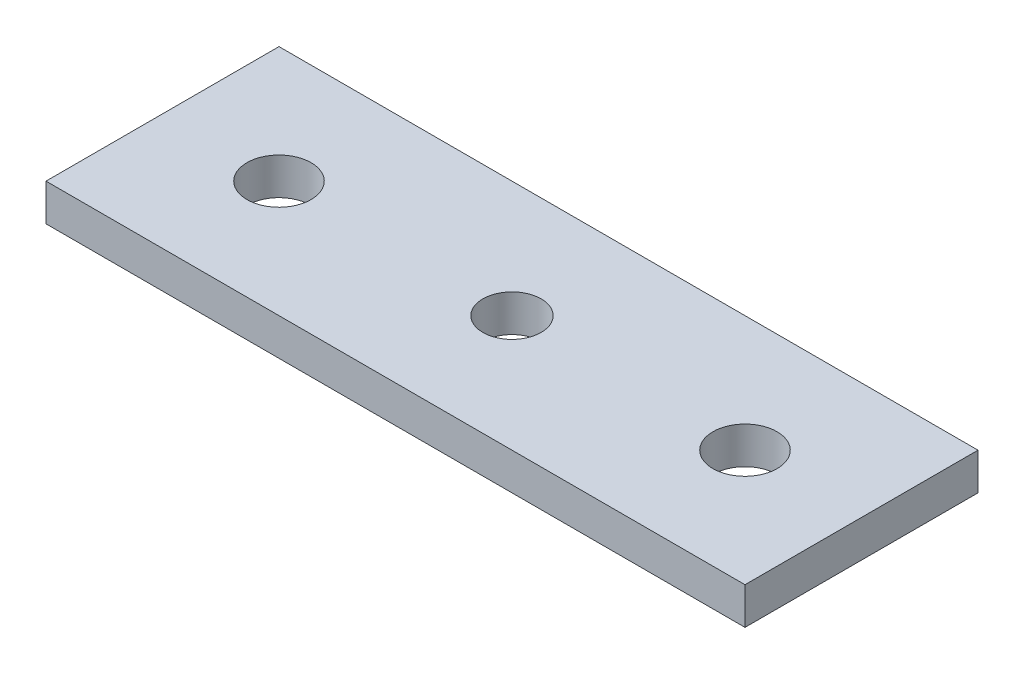
from build123d import *

# Parameters (mm, degrees)
SKETCH1_W             = 60
SKETCH1_H             = 20
BOSS_EXTRUDE1_DEPTH   = 3.175
SKETCH4_R             = 2.75
CUT_EXTRUDE1_DEPTH    = 3.175
M6X1_0_TAPPED_HOLE1_D = 5


with BuildPart() as part:
    # Sketch1 → Boss-Extrude1 (new body)
    with BuildSketch(Plane(origin=(0, 0, 0), x_dir=(1, 0, 0), z_dir=(0, 1, 0))):
        with Locations((30, 10)):
            Rectangle(SKETCH1_W, SKETCH1_H)
    extrude(amount=BOSS_EXTRUDE1_DEPTH)

    # Sketch4 → Cut-Extrude1 (cut)
    with BuildSketch(Plane.XZ):
        with Locations((50, -10)):
            Circle(SKETCH4_R)
        with Locations((10, -10)):
            Circle(SKETCH4_R)
    extrude(amount=-CUT_EXTRUDE1_DEPTH, mode=Mode.SUBTRACT)

    # M6x1.0 Tapped Hole1 (through all)
    with Locations(Plane(origin=(30, 0, -10), x_dir=(0, 0, -1), z_dir=(0, -1, 0))):
        with Locations((0, 0)):
            Hole(M6X1_0_TAPPED_HOLE1_D / 2)


solid = part.part
